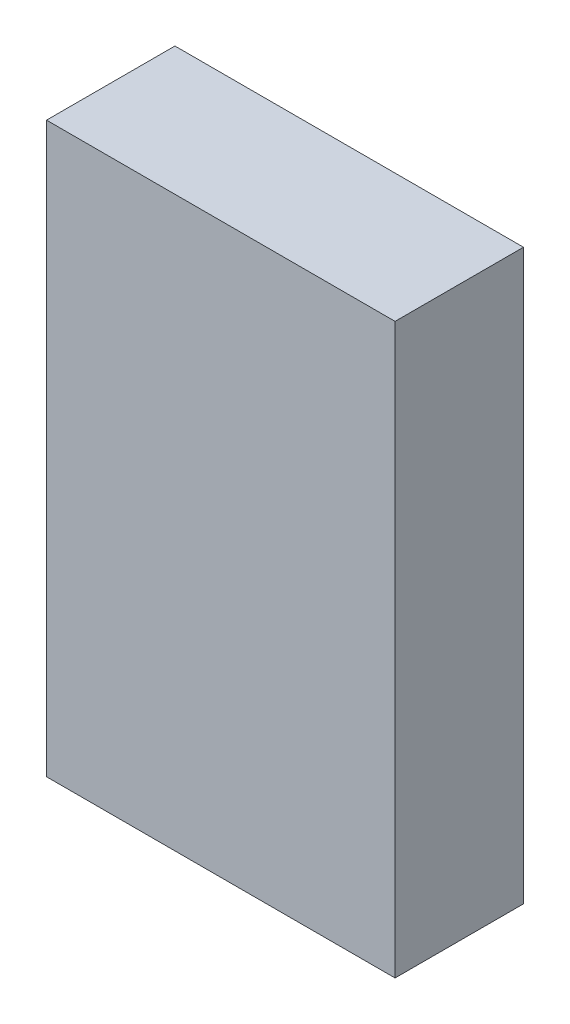
from build123d import *

# Parameters (mm, degrees)
SKETCH1_W           = 38
SKETCH1_H           = 62
BOSS_EXTRUDE1_DEPTH = 14


with BuildPart() as part:
    # Sketch1 → Boss-Extrude1 (new body)
    with BuildSketch(Plane.XY):
        Rectangle(SKETCH1_W, SKETCH1_H)
    extrude(amount=BOSS_EXTRUDE1_DEPTH)


solid = part.part
